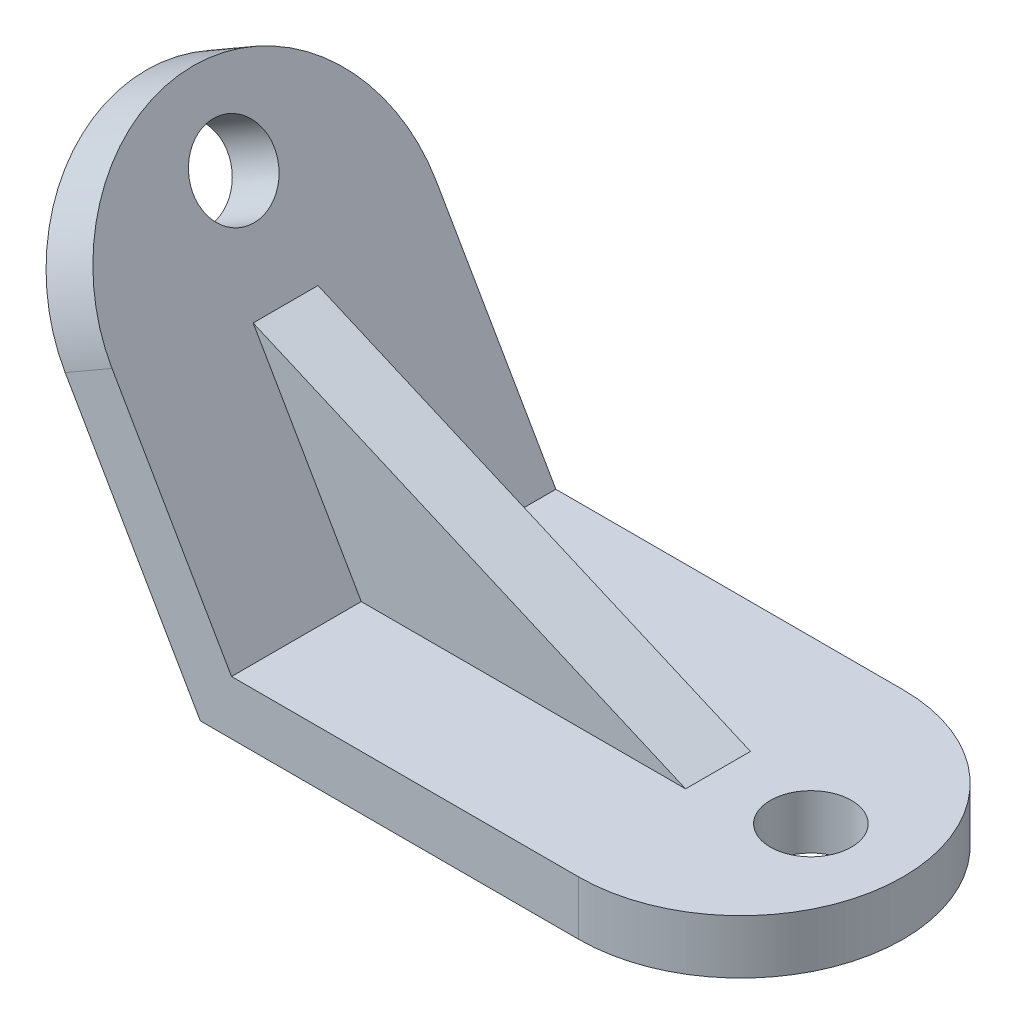
from build123d import *

# Parameters (mm, degrees)
BOSS_EXTRUDE1_DEPTH = 30
CUT_EXTRUDE1_DEPTH  = 60
CUT_EXTRUDE2_DEPTH  = 60
BOSS_EXTRUDE2_DEPTH = 6
SKETCH6_R           = 7.5
CUT_EXTRUDE3_DEPTH  = 12
SKETCH7_R           = 7.5
CUT_EXTRUDE4_DEPTH  = 12


with BuildPart() as part:
    # Sketch2 → Boss-Extrude1 (new body, symmetric)
    with BuildSketch(Plane.XY):
        Polygon((100, 0), (0, 0), (-40, 69.282032303), (-31.339745962, 74.282032303), (5.773502692, 10), (100, 10), align=None)
    extrude(amount=BOSS_EXTRUDE1_DEPTH, both=True)

    # Sketch3 → Cut-Extrude1 (cut)
    with BuildSketch(Plane(origin=(0, 10, 0), x_dir=(1, 0, 0), z_dir=(0, 1, 0))):
        with BuildLine():
            ThreePointArc((70, 30), (91.213203452, 21.213203419), (100, -4.6e-08))
            Line((100, -4.6e-08), (100, 30))
            Line((100, 30), (70, 30))
        make_face()
        with BuildLine():
            Line((70, -30), (100, -30))
            Line((100, -30), (100, -4.6e-08))
            ThreePointArc((100, -4.6e-08), (91.213203419, -21.213203452), (70, -30))
        make_face()
    extrude(amount=-CUT_EXTRUDE1_DEPTH, mode=Mode.SUBTRACT)

    # Sketch4 → Cut-Extrude2 (cut)
    with BuildSketch(Plane(origin=(8.660254038, 5, 0), x_dir=(0, 0, -1), z_dir=(0.866025404, 0.5, 0))):
        with BuildLine():
            ThreePointArc((-30, 50), (-21.213203436, 71.213203436), (0, 80))
            Line((0, 80), (-30, 80))
            Line((-30, 80), (-30, 50))
        make_face()
        with BuildLine():
            ThreePointArc((0, 80), (21.213203436, 71.213203436), (30, 50))
            Line((30, 50), (30, 80))
            Line((30, 80), (0, 80))
        make_face()
    extrude(amount=-CUT_EXTRUDE2_DEPTH, mode=Mode.SUBTRACT)

    # Sketch5 → Boss-Extrude2 (add, symmetric)
    with BuildSketch(Plane.XY):
        Polygon((5.773502692, 10), (65.773502692, 10), (-14.226497308, 44.641016151), align=None)
    extrude(amount=BOSS_EXTRUDE2_DEPTH, both=True)

    # Sketch6 → Cut-Extrude3 (cut)
    with BuildSketch(Plane(origin=(0, 10, 0), x_dir=(1, 0, 0), z_dir=(0, 1, 0))):
        with Locations((82.951530003, 0)):
            Circle(SKETCH6_R)
    extrude(amount=-CUT_EXTRUDE3_DEPTH, mode=Mode.SUBTRACT)

    # Sketch7 → Cut-Extrude4 (cut)
    with BuildSketch(Plane(origin=(0, 0, 0), x_dir=(0, 0, 1), z_dir=(-0.866025404, -0.5, 0))):
        with Locations((0, 64.952644295)):
            Circle(SKETCH7_R)
    extrude(amount=-CUT_EXTRUDE4_DEPTH, mode=Mode.SUBTRACT)


solid = part.part
